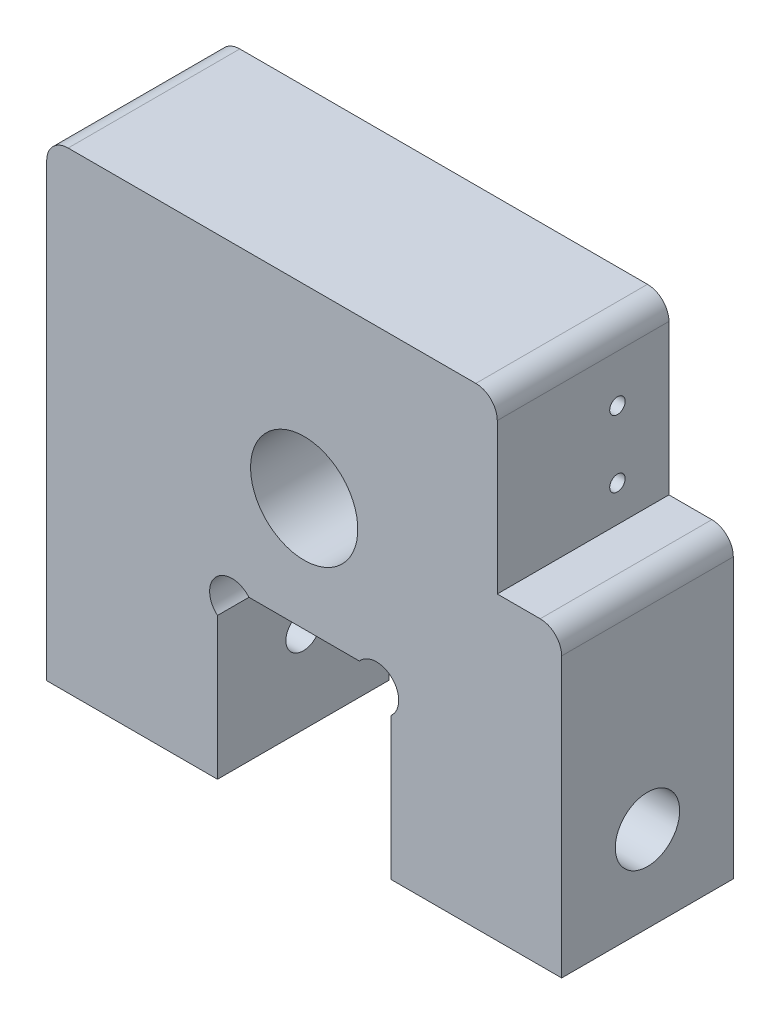
from build123d import *

# Parameters (mm, degrees)
SKETCH1_R           = 6.35
BOSS_EXTRUDE1_DEPTH = 25.4
SKETCH2_R           = 7.9375
CUT_EXTRUDE1_DEPTH  = 26.4
FILLET1_R           = 3.175
CUT_EXTRUDE2_START  = -76.2
SKETCH3_R           = 2.5796875
CUT_EXTRUDE2_DEPTH  = 76.2
SKETCH4_R           = 1.35255
CUT_EXTRUDE3_DEPTH  = 15.748
SKETCH5_R           = 4.7625
CUT_EXTRUDE4_DEPTH  = 10.3886
SKETCH6_R           = 1.143
CUT_EXTRUDE5_DEPTH  = 6.35


with BuildPart() as part:
    # Sketch1 → Boss-Extrude1 (new body)
    with BuildSketch(Plane.XY):
        with BuildLine():
            Line((38.1, -34.925), (12.827, -34.925))
            Line((12.827, -34.925), (12.827, -13.92549629))
            ThreePointArc((12.827, -13.92549629), (13.023080834, -9.074919166), (8.17250371, -9.271))
            Line((8.17250371, -9.271), (-8.17250371, -9.271))
            ThreePointArc((-8.17250371, -9.271), (-13.023080834, -9.074919166), (-12.827, -13.92549629))
            Line((-12.827, -13.92549629), (-12.827, -34.925))
            Line((-12.827, -34.925), (-38.1, -34.925))
            Line((-38.1, -34.925), (-38.1, 34.925))
            Line((-38.1, 34.925), (28.575, 34.925))
            Line((28.575, 34.925), (28.575, 30.099))
            Line((28.575, 30.099), (28.575, 9.525))
            Line((28.575, 9.525), (38.1, 9.525))
            Line((38.1, 9.525), (38.1, -34.925))
        make_face()
        with Locations((0, 7.493)):
            Circle(SKETCH1_R, mode=Mode.SUBTRACT)
    extrude(amount=BOSS_EXTRUDE1_DEPTH)

    # Sketch2 → Cut-Extrude1 (cut, through all)
    with BuildSketch(Plane(origin=(0, 0, 0), x_dir=(-1, 0, 0), z_dir=(0, 0, -1))):
        with Locations((0, 7.493)):
            Circle(SKETCH2_R)
    extrude(amount=-CUT_EXTRUDE1_DEPTH, mode=Mode.SUBTRACT)

    # Fillet1
    fillet1_edges = [part.edges().sort_by_distance(p)[0] for p in [
        (-38.1, 34.925, 12.7),
        (28.575, 34.925, 12.7),
        (38.1, 9.525, 12.7),
    ]]
    fillet(fillet1_edges, radius=FILLET1_R)

    # Sketch3 → Cut-Extrude2 (cut)
    with BuildSketch(Plane(origin=(38.1, 0, 0), x_dir=(0, 0, -1), z_dir=(1, 0, 0)).offset(CUT_EXTRUDE2_START)):
        with Locations((-12.7, -22.225)):
            Circle(SKETCH3_R)
    extrude(amount=CUT_EXTRUDE2_DEPTH, mode=Mode.SUBTRACT)

    # Sketch4 → Cut-Extrude3 (cut)
    with BuildSketch(Plane.ZY.offset(38.1)):
        with Locations((12.7, 28.575)):
            Circle(SKETCH4_R)
    extrude(amount=-CUT_EXTRUDE3_DEPTH, mode=Mode.SUBTRACT)

    # Sketch5 → Cut-Extrude4 (cut)
    with BuildSketch(Plane(origin=(38.1, 0, 0), x_dir=(0, 0, -1), z_dir=(1, 0, 0))):
        with Locations((-12.7, -22.225)):
            Circle(SKETCH5_R)
    cut_extrude4 = extrude(amount=-CUT_EXTRUDE4_DEPTH, mode=Mode.SUBTRACT)

    # Mirror1: Cut-Extrude4 across plane
    add(cut_extrude4.mirror(Plane(origin=(0, 0, 0), x_dir=(0, 0, 1), z_dir=(1, 0, 0))), mode=Mode.SUBTRACT)

    # Sketch6 → Cut-Extrude5 (cut)
    with BuildSketch(Plane(origin=(28.575, 0, 0), x_dir=(0, 0, -1), z_dir=(1, 0, 0))):
        with Locations((-7.62, 14.859)):
            Circle(SKETCH6_R)
        with Locations((-7.62, 24.765)):
            Circle(SKETCH6_R)
    extrude(amount=-CUT_EXTRUDE5_DEPTH, mode=Mode.SUBTRACT)


solid = part.part
